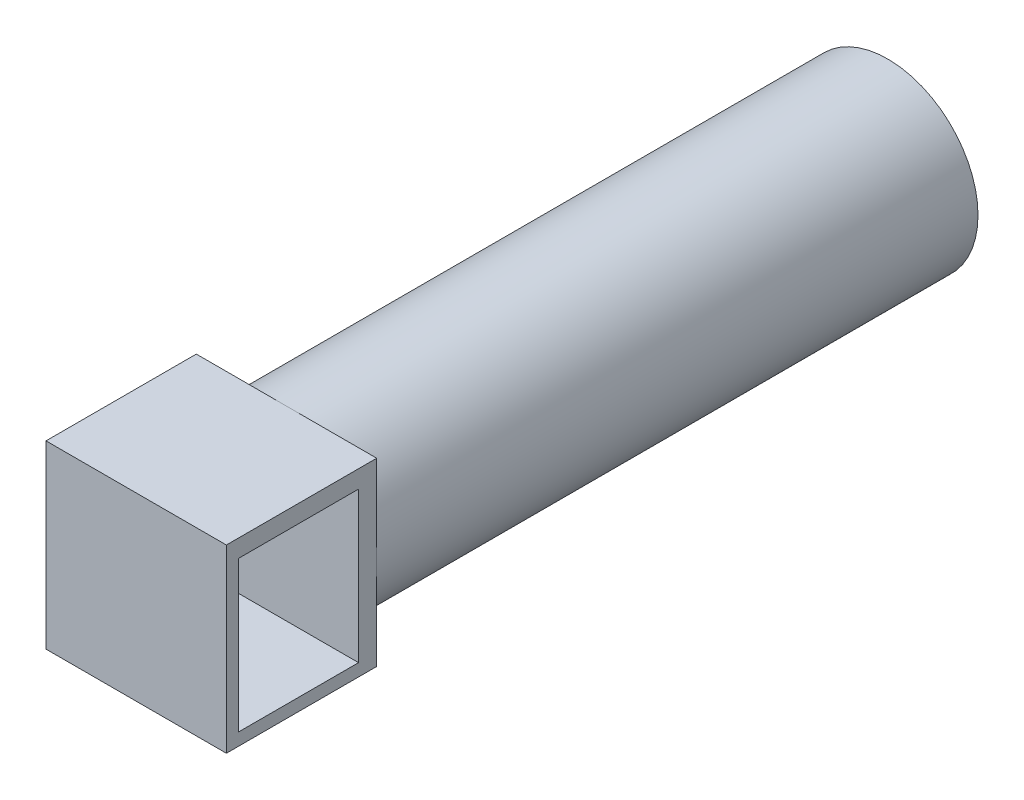
from build123d import *

# Parameters (mm, degrees)
SZKIC1_R                    = 30
DODANIE_WYCI_GNI_CIE1_DEPTH = 200
SZKIC2_W                    = 50
SZKIC2_H                    = 60
DODANIE_WYCI_GNI_CIE2_DEPTH = 30
SZKIC3_W                    = 40
SZKIC3_H                    = 50
WYTNIJ_WYCI_GNI_CIE1_DEPTH  = 61


with BuildPart() as part:
    # Szkic1 → Dodanie-wyciągnięcie1 (new body)
    with BuildSketch(Plane.XY):
        Circle(SZKIC1_R)
    extrude(amount=DODANIE_WYCI_GNI_CIE1_DEPTH)

    # Szkic2 → Dodanie-wyciągnięcie2 (add, symmetric)
    with BuildSketch(Plane(origin=(0, 0, 0), x_dir=(0, 0, -1), z_dir=(1, 0, 0))):
        with Locations((-225, 0)):
            Rectangle(SZKIC2_W, SZKIC2_H)
    extrude(amount=DODANIE_WYCI_GNI_CIE2_DEPTH, both=True)

    # Szkic3 → Wytnij-wyciągnięcie1 (cut, through all)
    with BuildSketch(Plane(origin=(30, 0, 0), x_dir=(0, 0, -1), z_dir=(1, 0, 0))):
        with Locations((-226.037911192, -0.873923737)):
            Rectangle(SZKIC3_W, SZKIC3_H)
    extrude(amount=-WYTNIJ_WYCI_GNI_CIE1_DEPTH, mode=Mode.SUBTRACT)


solid = part.part
